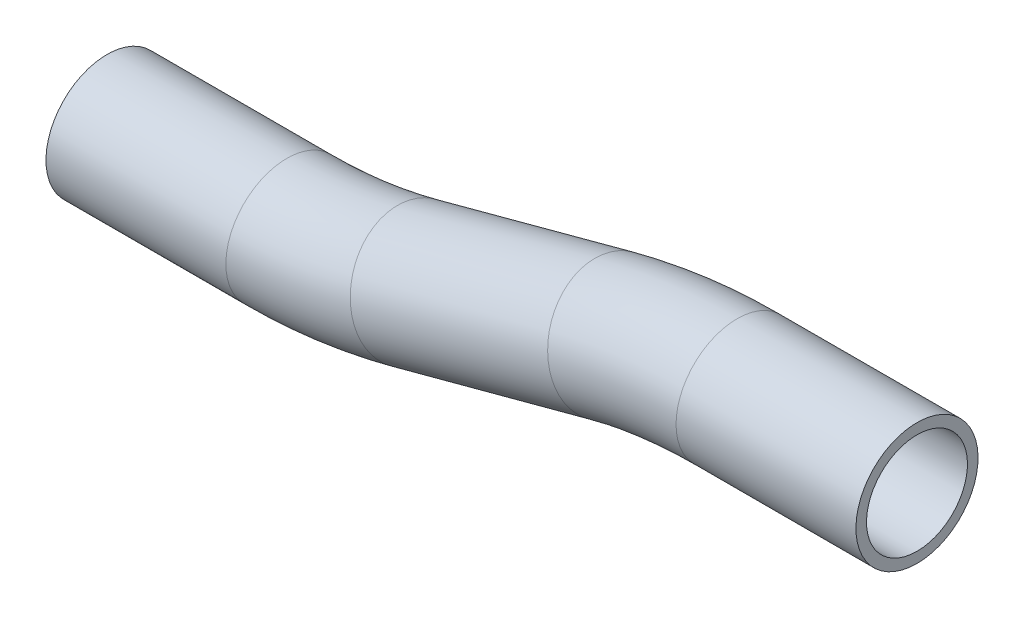
from build123d import *

# Parameters (mm, degrees)
SKETCH2_R   = 9.525
SKETCH2_R_2 = 7.874


with BuildPart() as part:
    # Sweep1: sweep along a path in Sketch1
    with BuildLine(Plane.XY) as sweep1_path:
        Line((28.068079684, 0), (0, 0))
        ThreePointArc((0, 0), (-9.946095847, -0.651901563), (-19.722011237, -2.596452037))
        Line((-19.722011237, -2.596452037), (-50.523992361, -10.849818004))
        ThreePointArc((-50.523992361, -10.849818004), (-60.299907751, -12.794368478), (-70.246003598, -13.446270041))
        Line((-70.246003598, -13.446270041), (-98.314083282, -13.446270041))
    # Sketch2 → Sweep1 (sweep)
    with BuildSketch(Plane.ZY.offset(-28.068079684)):
        Circle(SKETCH2_R)
        Circle(SKETCH2_R_2, mode=Mode.SUBTRACT)
    sweep(path=sweep1_path.line)


solid = part.part
